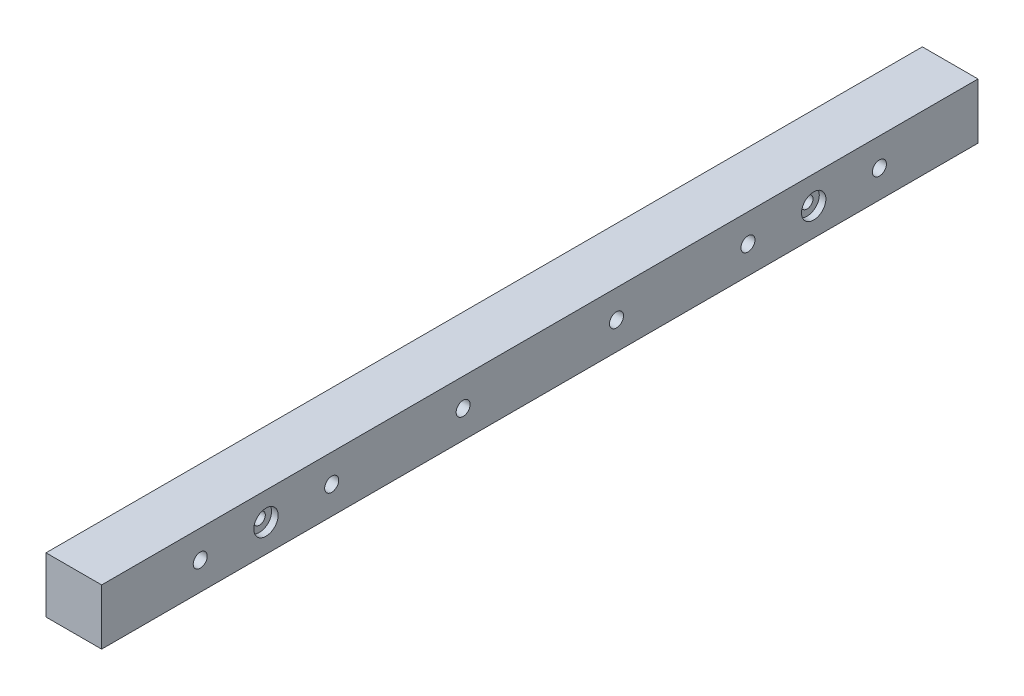
from build123d import *

# Parameters (mm, degrees)
BOSS_EXTRUDE1_DEPTH      = 200
BOSS_EXTRUDE1_DEPTH_BACK = 200
SKETCH1_W                = 25.4
SKETCH1_H                = 25.4
SKETCH5_R                = 3.2
CUT_EXTRUDE1_DEPTH       = 203.006064265
SKETCH6_R                = 4
CUT_EXTRUDE2_DEPTH       = 3


with BuildPart() as part:
    # Sketch1 → Boss-Extrude1 (new, two sides: drawn at the far end of the back side and taken through both)
    with BuildSketch(Plane.XY.offset(-BOSS_EXTRUDE1_DEPTH_BACK)):
        Rectangle(SKETCH1_W, SKETCH1_H)
    extrude(amount=BOSS_EXTRUDE1_DEPTH + BOSS_EXTRUDE1_DEPTH_BACK)

    # Sketch5 → Cut-Extrude1 (cut, through all)
    with BuildSketch(Plane(origin=(12.7, 0, 0), x_dir=(0, 0, -1), z_dir=(1, 0, 0))):
        with Locations((-155, 0)):
            Circle(SKETCH5_R)
        with Locations((-95, 0)):
            Circle(SKETCH5_R)
        with Locations((-35, 0)):
            Circle(SKETCH5_R)
        with Locations((35, 0)):
            Circle(SKETCH5_R)
        with Locations((95, 0)):
            Circle(SKETCH5_R)
        with Locations((155, 0)):
            Circle(SKETCH5_R)
    extrude(amount=-CUT_EXTRUDE1_DEPTH, mode=Mode.SUBTRACT)

    # Sketch6 → Cut-Extrude2 (cut)
    with BuildSketch(Plane.ZY.offset(12.7)):
        with Locations((-155, 0)):
            Circle(SKETCH6_R)
        with Locations((-95, 0)):
            Circle(SKETCH6_R)
        with Locations((-35, 0)):
            Circle(SKETCH6_R)
        with Locations((35, 0)):
            Circle(SKETCH6_R)
        with Locations((95, 0)):
            Circle(SKETCH6_R)
        with Locations((155, 0)):
            Circle(SKETCH6_R)
    extrude(amount=-CUT_EXTRUDE2_DEPTH, mode=Mode.SUBTRACT)

    # Sketch7 → Cut-Revolve1 (revolve, cut)
    with BuildSketch(Plane(origin=(0, 0, 0), x_dir=(1, 0, 0), z_dir=(0, 1, 0))):
        Polygon((-12.7, 125), (-12.7, 119), (2.3, 119), (4.205255888, 122.3), (9.7, 122.3), (9.7, 119.44375), (12.7, 119.44375), (12.7, 125), align=None)
    cut_revolve1 = revolve(axis=Axis((12.7, 0, -125), (-1, 0, 0)), mode=Mode.SUBTRACT)

    # Mirror1: Cut-Revolve1 across plane
    add(cut_revolve1.mirror(Plane.XY), mode=Mode.SUBTRACT)


solid = part.part
